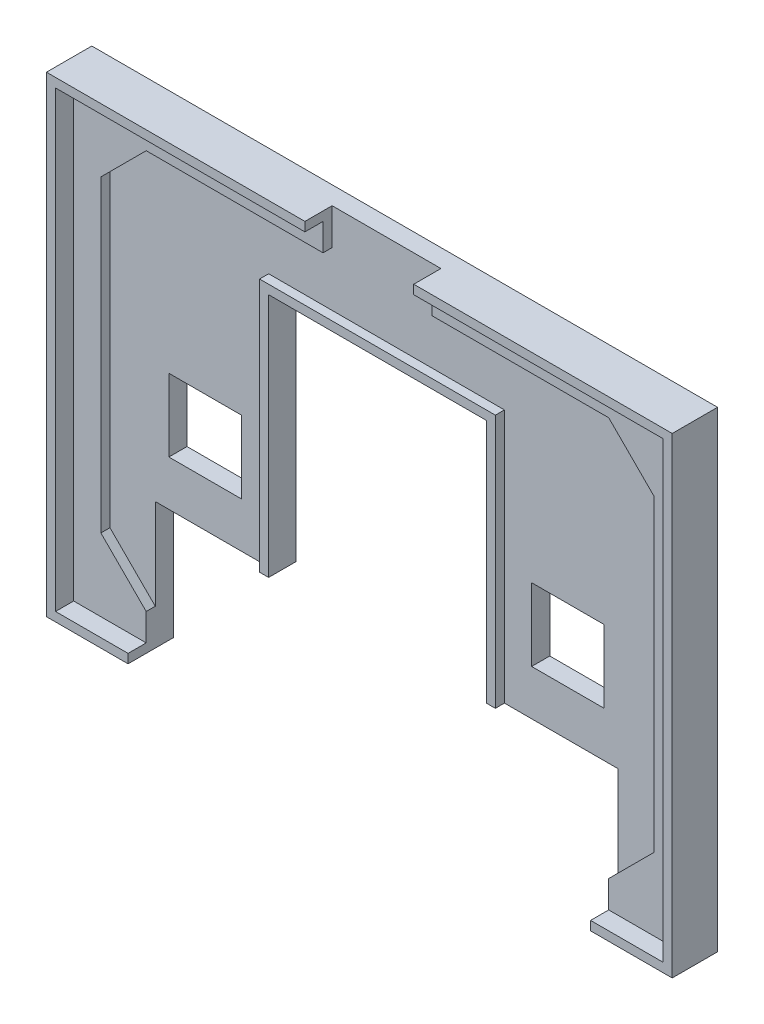
from build123d import *

# Parameters (mm, degrees)
SKICA1_W                    = 67
SKICA1_H                    = 50
P_IDAT_VYSUNUT_M1_DEPTH     = 3
ODEBRAT_VYSUNUT_M1_DEPTH    = 1
SKICA3_W                    = 8
SKICA3_H                    = 8
ODEBRAT_VYSUNUT_M2_DEPTH    = 4
VYSUNOUT_TENKOST_NN_1_DEPTH = 1
VYSUNOUT_TENKOST_NN_2_DEPTH = 5
SKICA6_W                    = 12
SKICA6_H                    = 4
ODEBRAT_VYSUNUT_M3_DEPTH    = 4
ODEBRAT_VYSUNUT_M4_DEPTH    = 1
SKICA8_W                    = 1.83786442
SKICA8_H                    = 3.44614173
SKICA8_W_2                  = 1.837864419
P_IDAT_VYSUNUT_M2_DEPTH     = 1
ODEBRAT_VYSUNUT_M5_DEPTH    = 1


with BuildPart() as part:
    # Skica1 → Přidat vysunutím1 (new body)
    with BuildSketch(Plane.XY):
        Rectangle(SKICA1_W, SKICA1_H)
    extrude(amount=P_IDAT_VYSUNUT_M1_DEPTH)

    # Skica2 → Odebrat vysunutím1 (cut)
    with BuildSketch(Plane.XY.offset(3)):
        Polygon((-25.5, -22), (-30.5, -17), (-30.5, 17), (-25.5, 22), (25.5, 22), (30.5, 17), (30.5, -17), (25.5, -22), align=None)
    extrude(amount=-ODEBRAT_VYSUNUT_M1_DEPTH, mode=Mode.SUBTRACT)

    # Skica3 → Odebrat vysunutím2 (cut, through all)
    with BuildSketch(Plane(origin=(0, 0, 0), x_dir=(-1, 0, 0), z_dir=(0, 0, -1))):
        with Locations((20, -3)):
            Rectangle(SKICA3_W, SKICA3_H)
        with Locations((-20, -3)):
            Rectangle(SKICA3_W, SKICA3_H)
        Polygon((25.5, -25), (-25.5, -25), (-25.5, -12), (-12, -12), (-12, 15), (12, 15), (12, -12), (25.5, -12), align=None)
    extrude(amount=-ODEBRAT_VYSUNUT_M2_DEPTH, mode=Mode.SUBTRACT)

    # Skica4 → Vysunout tenkostěnný1 (add)
    with BuildSketch(Plane.XY.offset(2)):
        Polygon((-12, -12), (-12, 15), (12, 15), (12, -12), (13, -12), (13, 16), (-13, 16), (-13, -12), align=None)
    extrude(amount=VYSUNOUT_TENKOST_NN_1_DEPTH)

    # Skica5 → Vysunout tenkostěnný2 (add)
    with BuildSketch(Plane(origin=(0, 0, 0), x_dir=(-1, 0, 0), z_dir=(0, 0, -1))):
        Polygon((-25.5, -25), (-33.5, -25), (-33.5, 25), (33.5, 25), (33.5, -25), (25.5, -25), (25.5, -26), (34.5, -26), (34.5, 26), (-34.5, 26), (-34.5, -26), (-25.5, -26), align=None)
    extrude(amount=-VYSUNOUT_TENKOST_NN_2_DEPTH)

    # Skica6 → Odebrat vysunutím3 (cut, through all)
    with BuildSketch(Plane.XY.offset(2)):
        with Locations((0, 24)):
            Rectangle(SKICA6_W, SKICA6_H)
    extrude(amount=ODEBRAT_VYSUNUT_M3_DEPTH, mode=Mode.SUBTRACT)

    # Skica7 → Odebrat vysunutím4 (cut)
    with BuildSketch(Plane(origin=(0, 0, 0), x_dir=(-1, 0, 0), z_dir=(0, 0, -1))):
        Polygon((-27.573500454, 21.535762152), (-25.735636034, 21.535762152), (-25.735636034, 19.662554186), (-20.752195973, 19.662554186), (-20.752195973, 21.535762152), (-18.843644461, 21.535762152), (-18.843644461, 18.001407499), (-17.111810681, 18.001407499), (-17.111810681, 16.269573719), (-15.379976901, 16.269573719), (-15.379976901, 7.433687086), (-17.111810681, 7.433687086), (-17.111810681, 10.8620111), (-18.843644461, 10.8620111), (-18.843644461, 5.737196853), (-22.377999114, 5.737196853), (-22.377999114, 7.433687086), (-20.610821787, 7.433687086), (-20.610821787, 9.077162), (-25.735636034, 9.077162), (-25.735636034, 7.433687086), (-23.968458708, 7.433687086), (-23.968458708, 5.737196853), (-27.573500454, 5.737196853), (-27.573500454, 10.8620111), (-29.34067778, 10.8620111), (-29.34067778, 7.433687086), (-31.107855107, 7.433687086), (-31.107855107, 16.269573719), (-29.34067778, 16.269573719), (-29.34067778, 18.001407499), (-27.573500454, 18.001407499), align=None)
        Polygon((22.377999114, 7.433687086), (20.610821787, 7.433687086), (20.610821787, 9.077162), (25.735636034, 9.077162), (25.735636034, 7.433687086), (23.968458708, 7.433687086), (23.968458708, 5.737196853), (27.573500454, 5.737196853), (27.573500454, 10.8620111), (29.34067778, 10.8620111), (29.34067778, 7.433687086), (31.107855107, 7.433687086), (31.107855107, 16.269573719), (29.34067778, 16.269573719), (29.34067778, 18.001407499), (27.573500454, 18.001407499), (27.573500454, 21.535762152), (25.735636034, 21.535762152), (25.735636034, 19.662554186), (20.752195973, 19.662554186), (20.752195973, 21.535762152), (18.843644461, 21.535762152), (18.843644461, 18.001407499), (17.111810681, 18.001407499), (17.111810681, 16.269573719), (15.379976901, 16.269573719), (15.379976901, 7.433687086), (17.111810681, 7.433687086), (17.111810681, 10.8620111), (18.843644461, 10.8620111), (18.843644461, 5.737196853), (22.377999114, 5.737196853), align=None)
    extrude(amount=-ODEBRAT_VYSUNUT_M4_DEPTH, mode=Mode.SUBTRACT)

    # Skica8 → Přidat vysunutím2 (add)
    with BuildSketch(Plane(origin=(0, 0, 1), x_dir=(-1, 0, 0), z_dir=(0, 0, -1))):
        with Locations((-26.654568244, 14.546502854)):
            Rectangle(SKICA8_W, SKICA8_H)
        with Locations((-19.691889577, 14.546502854)):
            Rectangle(SKICA8_W_2, SKICA8_H)
        with Locations((26.654568244, 14.546502854)):
            Rectangle(SKICA8_W, SKICA8_H)
        with Locations((19.691889577, 14.546502854)):
            Rectangle(SKICA8_W_2, SKICA8_H)
    extrude(amount=P_IDAT_VYSUNUT_M2_DEPTH)

    # Skica9 → Odebrat vysunutím5 (cut)
    with BuildSketch(Plane(origin=(0, 0, 0), x_dir=(-1, 0, 0), z_dir=(0, 0, -1))):
        with BuildLine():
            add(Edge.make_bspline(
                [(-9.537302345, 22.865597127), (-9.53696281, 22.892369552), (-9.536324143, 22.942728609), (-9.534519623, 23.0139512), (-9.529220507, 23.076239297), (-9.524308014, 23.129694286), (-9.515382011, 23.173526163), (-9.506637177, 23.209064992), (-9.494807146, 23.235008133), (-9.482756683, 23.254235867), (-9.46291792, 23.26163155), (-9.437741649, 23.267220572), (-9.400249505, 23.271288385), (-9.351541162, 23.276113687), (-9.290765442, 23.280804467), (-9.21846664, 23.285819108), (-9.134092167, 23.288841475), (-9.038213727, 23.292938181), (-8.930287005, 23.294799885), (-8.810406456, 23.297232369), (-8.678543151, 23.300109611), (-8.535059303, 23.300207146), (-8.37963407, 23.304162308), (-8.212576506, 23.302494115), (-8.033557672, 23.304964342), (-7.846934424, 23.304068462), (-7.660311177, 23.304964341), (-7.481292343, 23.30249412), (-7.31423478, 23.304162294), (-7.158809543, 23.300207193), (-7.015325708, 23.300109455), (-6.883462361, 23.297232877), (-6.763581948, 23.294798247), (-6.655654791, 23.292943383), (-6.559777713, 23.28882527), (-6.475797608, 23.285882631), (-6.403510582, 23.280691132), (-6.342726041, 23.276149909), (-6.294001793, 23.271407931), (-6.256945935, 23.26710668), (-6.232146004, 23.261635849), (-6.212319202, 23.254232462), (-6.200205343, 23.235024841), (-6.188701521, 23.208870011), (-6.178001896, 23.173785016), (-6.169745049, 23.129640249), (-6.164585879, 23.07625762), (-6.159369388, 23.013945286), (-6.15753857, 22.942730409), (-6.156903909, 22.892370177), (-6.156566504, 22.865597127)],
                knots=[0, 0, 0, 0, 8.0331e-05, 0.000151104, 0.000213628, 0.000267908, 0.000311874, 0.000347939, 0.000376911, 0.000398255, 0.000412741, 0.000438621, 0.000476093, 0.000525479, 0.000585612, 0.000658899, 0.000742895, 0.00083887, 0.000946792, 0.0010667, 0.001198595, 0.001342461, 0.00149713, 0.001664968, 0.0018436, 0.002034216, 0.002224831, 0.002403463, 0.002571301, 0.00272597, 0.002869836, 0.003001731, 0.003121639, 0.003229562, 0.003325536, 0.003409532, 0.003481623, 0.003542951, 0.003592337, 0.003628621, 0.0036545, 0.003668986, 0.003690331, 0.003719302, 0.003755704, 0.003799671, 0.003853951, 0.003916475, 0.003987247, 0.004067578, 0.004067578, 0.004067578, 0.004067578], degree=3))
            Line((-6.156566504, 22.865597127), (-6.156566504, 22.517932803))
            Line((-6.156566504, 22.517932803), (-5.891622312, 22.517932803))
            add(Edge.make_bspline(
                [(-5.891622312, 22.517932803), (-5.852723493, 22.517789452), (-5.78304439, 22.517532668), (-5.692036559, 22.503665866), (-5.621255973, 22.487521351), (-5.589784995, 22.461797975), (-5.576326735, 22.450797623)],
                knots=[0, 0, 0, 0, 0.000116343, 0.000208405, 0.000277419, 0.000328983, 0.000328983, 0.000328983, 0.000328983], degree=3))
            add(Edge.make_bspline(
                [(-5.576326735, 22.450797623), (-5.571078392, 22.438539971), (-5.556226275, 22.403852435), (-5.548489219, 22.33013994), (-5.540058826, 22.224075264), (-5.536293356, 22.126327559), (-5.534302457, 22.045593495), (-5.532715694, 21.989251146), (-5.533583626, 21.921702143), (-5.531797567, 21.842587005), (-5.530355252, 21.7518775), (-5.531281794, 21.649965942), (-5.528955975, 21.536885366), (-5.530123341, 21.412196073), (-5.527866149, 21.27593602), (-5.528435285, 21.128074363), (-5.528731851, 20.969025672), (-5.526712584, 20.798396067), (-5.527309573, 20.61656813), (-5.527134352, 20.423155484), (-5.52718652, 20.218552856), (-5.527167895, 20.006357772), (-5.527186426, 19.794162687), (-5.527134697, 19.589560061), (-5.527308031, 19.396547019), (-5.526718675, 19.214719133), (-5.528725951, 19.04448906), (-5.528434927, 18.885440407), (-5.52786641, 18.73797837), (-5.530121476, 18.601718296), (-5.528958534, 18.476629468), (-5.531282984, 18.363149186), (-5.53034846, 18.261237569), (-5.531823573, 18.170528333), (-5.533580154, 18.091413443), (-5.532715724, 18.023462852), (-5.534307395, 17.967126508), (-5.53626449, 17.886363393), (-5.540382501, 17.78932495), (-5.547637654, 17.682705023), (-5.558146632, 17.610912237), (-5.571867618, 17.563688116), (-5.59859442, 17.542295922), (-5.62702887, 17.527764426), (-5.663607461, 17.51706222), (-5.700922273, 17.513128423), (-5.739311224, 17.509734895), (-5.780936464, 17.509185174), (-5.834071768, 17.507806753), (-5.899214547, 17.506675501), (-5.97593962, 17.505547254), (-6.064250615, 17.503997914), (-6.164559488, 17.504487084), (-6.235290738, 17.504412885), (-6.272854226, 17.504373481)],
                knots=[0, 0, 0, 0, 3.9851e-05, 0.000112774, 0.000219801, 0.000360193, 0.000405765, 0.000462123, 0.000529259, 0.000608391, 0.000699511, 0.000801413, 0.00091411, 0.00103879, 0.001175463, 0.001322921, 0.001482367, 0.001652607, 0.001834831, 0.002027844, 0.002232847, 0.002448638, 0.00266443, 0.002869432, 0.003062446, 0.003243471, 0.003414909, 0.003573157, 0.003720614, 0.003857288, 0.003981967, 0.004095864, 0.004197765, 0.004287686, 0.004368018, 0.004435153, 0.004491511, 0.004537083, 0.004677476, 0.004783307, 0.00485623, 0.004897638, 0.004924817, 0.004955918, 0.004993467, 0.005038227, 0.005068294, 0.005109072, 0.005163033, 0.005227782, 0.005304517, 0.00539324, 0.005492744, 0.005605435, 0.005605435, 0.005605435, 0.005605435], degree=3))
            add(Edge.make_bspline(
                [(-6.272854226, 17.504373481), (-6.324403043, 17.504710075), (-6.420713213, 17.505338944), (-6.555837389, 17.507146882), (-6.671289532, 17.512276273), (-6.76820543, 17.517440625), (-6.845557691, 17.526035537), (-6.904848352, 17.534269772), (-6.943876859, 17.545512081), (-6.974876687, 17.561192112), (-6.98047961, 17.605365931), (-6.98927877, 17.667625557), (-6.997292171, 17.766317362), (-7.002106362, 17.896654209), (-7.008606407, 18.060641821), (-7.01298569, 18.257615902), (-7.016591708, 18.487418532), (-7.017859008, 18.651665879), (-7.018534259, 18.739181253)],
                knots=[0, 0, 0, 0, 0.000154655, 0.000288947, 0.000405334, 0.000501428, 0.000579804, 0.000639325, 0.000679517, 0.000703792, 0.000736404, 0.000801683, 0.000899151, 0.001029962, 0.001194313, 0.001390982, 0.001621188, 0.001883745, 0.001883745, 0.001883745, 0.001883745], degree=3))
            Line((-7.018534259, 18.739181253), (-7.018534259, 19.857701302))
            Line((-7.018534259, 19.857701302), (-8.67533459, 19.857701302))
            Line((-8.67533459, 19.857701302), (-8.67533459, 18.739181253))
            add(Edge.make_bspline(
                [(-8.67533459, 18.739181253), (-8.676021969, 18.651666572), (-8.67731203, 18.487420527), (-8.680770593, 18.257609466), (-8.685593662, 18.060660761), (-8.690831645, 17.896580792), (-8.699003804, 17.766447887), (-8.703592034, 17.667485718), (-8.71474526, 17.605319136), (-8.720214864, 17.561757534), (-8.75040145, 17.544793262), (-8.789652581, 17.53486673), (-8.848607616, 17.52571627), (-8.925698759, 17.517543697), (-9.022566689, 17.512239443), (-9.138035701, 17.507159253), (-9.273154314, 17.505335087), (-9.369465345, 17.504708731), (-9.421014623, 17.504373481)],
                knots=[0, 0, 0, 0, 0.000262557, 0.000492763, 0.000689432, 0.000853783, 0.000984654, 0.001082027, 0.001147471, 0.001180083, 0.00120336, 0.001244698, 0.001303037, 0.001381412, 0.001477506, 0.001593893, 0.001728185, 0.00188284, 0.00188284, 0.00188284, 0.00188284], degree=3))
            add(Edge.make_bspline(
                [(-9.421014623, 17.504373481), (-9.458578116, 17.504412698), (-9.529309373, 17.504486542), (-9.629618193, 17.503999705), (-9.717929358, 17.505541657), (-9.795053408, 17.506698175), (-9.860197757, 17.507765307), (-9.913730353, 17.509224745), (-9.955359061, 17.509704814), (-9.993749275, 17.513066496), (-10.030680832, 17.517128898), (-10.067064698, 17.528096268), (-10.096252337, 17.541942309), (-10.123174228, 17.563737006), (-10.13693763, 17.610884023), (-10.147408011, 17.682718967), (-10.154781621, 17.789318015), (-10.158471645, 17.886367346), (-10.161149191, 17.967118126), (-10.160281969, 18.023479448), (-10.162114937, 18.09140369), (-10.163495981, 18.170524728), (-10.162622963, 18.261247941), (-10.164809917, 18.363138899), (-10.164222961, 18.476635324), (-10.163958495, 18.601717143), (-10.165938682, 18.737978718), (-10.165452937, 18.885440304), (-10.165137175, 19.044489091), (-10.167151854, 19.214719124), (-10.166560324, 19.396547021), (-10.166734297, 19.589560061), (-10.166682377, 19.794162687), (-10.166700977, 20.006357772), (-10.166682283, 20.218552856), (-10.166734644, 20.423155485), (-10.166558777, 20.616568128), (-10.167157967, 20.798396076), (-10.165131254, 20.96902564), (-10.165452909, 21.128074469), (-10.165938407, 21.275935667), (-10.163958453, 21.412197241), (-10.164222472, 21.536879451), (-10.164804074, 21.649976211), (-10.162612906, 21.751867198), (-10.163508038, 21.84259042), (-10.162101412, 21.921711874), (-10.16028026, 21.989234325), (-10.161156003, 22.045602483), (-10.158433457, 22.12632027), (-10.155213791, 22.224121165), (-10.146306155, 22.330035059), (-10.13934322, 22.404212656), (-10.123264921, 22.438569033), (-10.117542114, 22.450797623)],
                knots=[0, 0, 0, 0, 0.000112691, 0.000212195, 0.000300918, 0.000377653, 0.0004436, 0.000496363, 0.000538339, 0.000568406, 0.000611979, 0.000649528, 0.000681696, 0.000708876, 0.000750283, 0.000823206, 0.000929038, 0.00106943, 0.001115002, 0.001171348, 0.001238493, 0.001318825, 0.001408738, 0.001510647, 0.001624537, 0.001749216, 0.00188589, 0.002033347, 0.002191594, 0.002363033, 0.002544058, 0.002737072, 0.002942074, 0.003157866, 0.003373657, 0.003578659, 0.003771673, 0.003953897, 0.004124137, 0.004283583, 0.004431041, 0.004567714, 0.004692394, 0.004805085, 0.004906993, 0.004998105, 0.005077238, 0.005144384, 0.00520073, 0.005246301, 0.005386694, 0.005493721, 0.005566643, 0.005606943, 0.005606943, 0.005606943, 0.005606943], degree=3))
            add(Edge.make_bspline(
                [(-10.117542114, 22.450797623), (-10.104501135, 22.46182427), (-10.073375573, 22.488142126), (-10.002078308, 22.50331256), (-9.910871706, 22.517640236), (-9.841162282, 22.517827989), (-9.802246537, 22.517932803)],
                knots=[0, 0, 0, 0, 5.0593e-05, 0.000120754, 0.000212815, 0.000329159, 0.000329159, 0.000329159, 0.000329159], degree=3))
            Line((-9.802246537, 22.517932803), (-9.537302345, 22.517932803))
            Line((-9.537302345, 22.517932803), (-9.537302345, 22.865597127))
        make_face()
        with BuildLine():
            add(Edge.make_bspline(
                [(-7.018534259, 20.951045659), (-7.018534259, 20.952644116), (-7.018534259, 20.959437557), (-7.018534259, 20.974223281), (-7.018534259, 20.999398973), (-7.018534259, 21.034165406), (-7.018534259, 21.079321807), (-7.018534259, 21.134068947), (-7.018534259, 21.198806442), (-7.018534259, 21.273534291), (-7.018534259, 21.358252494), (-7.018534259, 21.452961051), (-7.018534259, 21.557659963), (-7.018534259, 21.672349228), (-7.018534259, 21.797028848), (-7.018534259, 21.931698822), (-7.018534259, 22.07635915), (-7.018534259, 22.176262691), (-7.018534259, 22.227812919)],
                knots=[0, 0, 0, 0, 4.795e-06, 2.038e-05, 4.4357e-05, 8.0322e-05, 0.00012468, 0.000179826, 0.000244564, 0.000318892, 0.00040401, 0.000498718, 0.000603018, 0.000718107, 0.000842786, 0.000977057, 0.001122117, 0.001276767, 0.001276767, 0.001276767, 0.001276767], degree=3))
            Line((-7.018534259, 22.227812919), (-7.838542527, 22.236204816))
            add(Edge.make_bspline(
                [(-7.838542527, 22.236204816), (-7.840540598, 22.236204816), (-7.848133267, 22.236204816), (-7.865316676, 22.236204816), (-7.893689282, 22.236204816), (-7.933650698, 22.236204816), (-7.984801312, 22.236204816), (-8.047540736, 22.236204816), (-8.121469356, 22.236204816), (-8.17461804, 22.236204816), (-8.202990646, 22.236204816)],
                knots=[0, 0, 0, 0, 5.994e-06, 2.2778e-05, 5.155e-05, 9.1112e-05, 0.000142662, 0.000205002, 0.00027933, 0.000364448, 0.000364448, 0.000364448, 0.000364448], degree=3))
            add(Edge.make_bspline(
                [(-8.202990646, 22.236204816), (-8.239360634, 22.236472862), (-8.307314685, 22.236973681), (-8.40198411, 22.233758035), (-8.48240014, 22.232026014), (-8.548214262, 22.228294912), (-8.600666772, 22.224442371), (-8.637355865, 22.217365375), (-8.66367911, 22.214588369), (-8.672305795, 22.205742852), (-8.67533459, 22.202637226)],
                knots=[0, 0, 0, 0, 0.000109095, 0.000203834, 0.000284192, 0.000350226, 0.000401999, 0.000440827, 0.000464381, 0.000477125, 0.000477125, 0.000477125, 0.000477125], degree=3))
            add(Edge.make_bspline(
                [(-8.67533459, 22.202637226), (-8.67533459, 22.198641084), (-8.67533459, 22.182256904), (-8.67533459, 22.165872723), (-8.67533459, 22.153484684)],
                knots=[0, 0, 0, 0, 1.1988e-05, 4.9153e-05, 4.9153e-05, 4.9153e-05, 4.9153e-05], degree=3))
            add(Edge.make_bspline(
                [(-8.67533459, 22.153484684), (-8.67558581, 22.133898334), (-8.676155206, 22.089505427), (-8.680786555, 22.017657224), (-8.682679381, 21.937702343), (-8.683377488, 21.882546488), (-8.683726487, 21.854972902)],
                knots=[0, 0, 0, 0, 5.8756e-05, 0.000133171, 0.000215926, 0.000298654, 0.000298654, 0.000298654, 0.000298654], degree=3))
            add(Edge.make_bspline(
                [(-8.683726487, 21.854972902), (-8.683334661, 21.836191001), (-8.682350828, 21.78903161), (-8.680509978, 21.712284199), (-8.6761957, 21.631621963), (-8.675595602, 21.579243263), (-8.67533459, 21.55646112)],
                knots=[0, 0, 0, 0, 5.6358e-05, 0.00014151, 0.000230297, 0.000298642, 0.000298642, 0.000298642, 0.000298642], degree=3))
            Line((-8.67533459, 21.55646112), (-8.67533459, 20.951045659))
            Line((-8.67533459, 20.951045659), (-7.018534259, 20.951045659))
        make_face(mode=Mode.SUBTRACT)
        with BuildLine():
            add(Edge.make_bspline(
                [(-4.711961295, 22.840421434), (-4.711320941, 22.86919954), (-4.710119857, 22.923177302), (-4.706068634, 22.999075078), (-4.702883994, 23.065060265), (-4.698465504, 23.121090802), (-4.692094732, 23.16698662), (-4.686782118, 23.202781013), (-4.680229587, 23.228883735), (-4.669104594, 23.250414134), (-4.649162131, 23.268020667), (-4.619645507, 23.282079923), (-4.582919303, 23.291165632), (-4.546229992, 23.295767099), (-4.507811901, 23.299013902), (-4.466192712, 23.299533198), (-4.412656456, 23.300977555), (-4.347513445, 23.302050198), (-4.270388938, 23.303204834), (-4.182077924, 23.304747407), (-4.081769056, 23.304260374), (-4.011037806, 23.304334248), (-3.973474317, 23.304373481)],
                knots=[0, 0, 0, 0, 8.635e-05, 0.000161963, 0.000227997, 0.000284546, 0.000330495, 0.000366956, 0.000393139, 0.00041084, 0.000438827, 0.000470996, 0.000508218, 0.00055179, 0.000581857, 0.000623834, 0.000676597, 0.000742544, 0.000819279, 0.000908001, 0.001007505, 0.001120197, 0.001120197, 0.001120197, 0.001120197], degree=3))
            add(Edge.make_bspline(
                [(-3.973474317, 23.304373481), (-3.921925552, 23.304037871), (-3.82561548, 23.303410842), (-3.690490671, 23.30159102), (-3.575040448, 23.296497659), (-3.478119092, 23.291230859), (-3.40117264, 23.28295685), (-3.341861516, 23.274056024), (-3.303389913, 23.263583011), (-3.276810639, 23.250484013), (-3.27213295, 23.225023138), (-3.267509324, 23.192053258), (-3.263227671, 23.140464791), (-3.258112827, 23.071909345), (-3.255193185, 22.985469365), (-3.251458448, 22.881598237), (-3.247948038, 22.760502513), (-3.244402182, 22.621837963), (-3.240498098, 22.465599232), (-3.238556052, 22.291351276), (-3.236151724, 22.0999374), (-3.233282307, 21.890945553), (-3.233053415, 21.664350401), (-3.229648471, 21.420199551), (-3.229090161, 21.158444564), (-3.228235716, 20.978219095), (-3.227794284, 20.885109322)],
                knots=[0, 0, 0, 0, 0.000154655, 0.000288947, 0.000405334, 0.000501428, 0.000579804, 0.000638142, 0.00067948, 0.000702757, 0.000719063, 0.000752972, 0.000804745, 0.000873247, 0.000959638, 0.001063999, 0.001185136, 0.00132305, 0.001480139, 0.001653988, 0.001845818, 0.00205443, 0.002281015, 0.00252559, 0.002786941, 0.003066273, 0.003066273, 0.003066273, 0.003066273], degree=3))
            Line((-3.227794284, 20.885109322), (-3.227794284, 18.582132885))
            Line((-3.227794284, 18.582132885), (-1.695673573, 18.573740988))
            add(Edge.make_bspline(
                [(-1.695673573, 18.573740988), (-1.634133339, 18.573311829), (-1.514649223, 18.57247859), (-1.341207004, 18.571754104), (-1.179371695, 18.56895203), (-1.02911465, 18.566687148), (-0.890451989, 18.564141869), (-0.762952274, 18.562231791), (-0.647081996, 18.558264823), (-0.542776506, 18.554836158), (-0.450072632, 18.551056639), (-0.368901239, 18.548009717), (-0.299372133, 18.543047373), (-0.241486103, 18.538025357), (-0.194846131, 18.534256638), (-0.159941546, 18.527547751), (-0.13551861, 18.523302161), (-0.124329089, 18.517158125), (-0.120394532, 18.514997706)],
                knots=[0, 0, 0, 0, 0.000184626, 0.000358462, 0.000520323, 0.000670198, 0.000809284, 0.000936384, 0.001052728, 0.001157089, 0.00124947, 0.00133107, 0.001400768, 0.001458512, 0.001505512, 0.001540792, 0.001565507, 0.00157891, 0.00157891, 0.00157891, 0.00157891], degree=3))
            add(Edge.make_bspline(
                [(-0.120394532, 18.514997706), (-0.116946255, 18.509517528), (-0.108356603, 18.495866413), (-0.101084836, 18.466520486), (-0.094264664, 18.426122029), (-0.088104796, 18.372868209), (-0.085745128, 18.307594471), (-0.081059982, 18.230127383), (-0.081025461, 18.140551488), (-0.080116675, 18.076618074), (-0.079633887, 18.042653762)],
                knots=[0, 0, 0, 0, 1.9331e-05, 4.8153e-05, 8.9543e-05, 0.000142632, 0.000208666, 0.000285476, 0.000375398, 0.000477306, 0.000477306, 0.000477306, 0.000477306], degree=3))
            add(Edge.make_bspline(
                [(-0.079633887, 18.042653762), (-0.079929666, 18.009884067), (-0.080485235, 17.948332024), (-0.082828046, 17.86119743), (-0.086472147, 17.78486262), (-0.090491959, 17.71918519), (-0.097944052, 17.664381873), (-0.105975099, 17.620772637), (-0.114492161, 17.586608981), (-0.124469946, 17.569373955), (-0.128786429, 17.561917921)],
                knots=[0, 0, 0, 0, 9.8312e-05, 0.000184662, 0.000261473, 0.000327583, 0.000382008, 0.000427152, 0.000460912, 0.000486652, 0.000486652, 0.000486652, 0.000486652], degree=3))
            add(Edge.make_bspline(
                [(-0.128786429, 17.561917921), (-0.139749315, 17.555340478), (-0.1698037, 17.537308641), (-0.2386661, 17.527746589), (-0.336484571, 17.516360826), (-0.427692823, 17.513592096), (-0.502817682, 17.511473549), (-0.555566771, 17.509916033), (-0.618719986, 17.510787156), (-0.692639678, 17.508988792), (-0.776955207, 17.507557936), (-0.872073994, 17.508478198), (-0.977561204, 17.506154768), (-1.093459721, 17.507324224), (-1.220128295, 17.505058174), (-1.357200789, 17.505636139), (-1.505460006, 17.50592521), (-1.664100848, 17.503916259), (-1.83354096, 17.504507733), (-2.012967076, 17.504334273), (-2.203183603, 17.504385718), (-2.400193347, 17.504367176), (-2.597602704, 17.504385785), (-2.787819236, 17.504333578), (-2.967644953, 17.504509124), (-3.136685498, 17.503912846), (-3.294926652, 17.505928466), (-3.442786297, 17.505635168), (-3.579858783, 17.505058385), (-3.70652736, 17.507324231), (-3.822425873, 17.50615458), (-3.928312659, 17.508487646), (-4.023431551, 17.50754661), (-4.107747165, 17.509001811), (-4.181266101, 17.510787235), (-4.244423301, 17.509913643), (-4.297161042, 17.511480633), (-4.372339805, 17.513553352), (-4.462566774, 17.516806131), (-4.561773304, 17.526594574), (-4.626487111, 17.539763701), (-4.668133605, 17.554462552), (-4.680064101, 17.580100093), (-4.686855467, 17.605860943), (-4.692066228, 17.641801263), (-4.698475549, 17.687641137), (-4.702882668, 17.743691816), (-4.706059149, 17.809670405), (-4.710168314, 17.885569178), (-4.711537087, 17.957135472), (-4.713635614, 18.025060722), (-4.712736813, 18.090614456), (-4.714556047, 18.169328855), (-4.715965063, 18.261637488), (-4.71507621, 18.36714498), (-4.717272124, 18.486220819), (-4.716682545, 18.618498271), (-4.716419407, 18.764359652), (-4.718396474, 18.923000612), (-4.717912284, 19.095237703), (-4.71759214, 19.280660716), (-4.719615844, 19.479663717), (-4.719018805, 19.691861829), (-4.719194361, 19.917643308), (-4.719141989, 20.15661273), (-4.719160682, 20.404373481), (-4.719141989, 20.652134231), (-4.719194361, 20.891103653), (-4.719018805, 21.116885133), (-4.719615844, 21.329083245), (-4.71759214, 21.528086246), (-4.717912285, 21.713509259), (-4.718396471, 21.88574635), (-4.716419417, 22.04438731), (-4.716682512, 22.19024869), (-4.717272233, 22.322526145), (-4.715075867, 22.441601974), (-4.715966132, 22.547109496), (-4.714552802, 22.63941804), (-4.712746283, 22.718132701), (-4.713609385, 22.783685701), (-4.712472021, 22.822839622), (-4.711961295, 22.840421434)],
                knots=[0, 0, 0, 0, 3.8081e-05, 0.000104398, 0.000204485, 0.000335296, 0.000377273, 0.000430035, 0.000493574, 0.000566713, 0.00065184, 0.000746548, 0.000852053, 0.000968341, 0.001094225, 0.001232092, 0.001379549, 0.001539, 0.001708037, 0.001887863, 0.00207728, 0.002278686, 0.002478892, 0.002669508, 0.002849335, 0.003018372, 0.003176623, 0.003324081, 0.003461948, 0.003587832, 0.00370412, 0.003809625, 0.003905532, 0.00398946, 0.004062599, 0.004126138, 0.0041789, 0.004220877, 0.004351688, 0.004450584, 0.0045169, 0.004554981, 0.004572682, 0.004598865, 0.004635326, 0.004681275, 0.004737824, 0.004803859, 0.004879471, 0.004965821, 0.005018584, 0.005083321, 0.005162454, 0.005254773, 0.005360271, 0.005478962, 0.005612034, 0.005757094, 0.005916544, 0.006087979, 0.006273799, 0.006472811, 0.006685006, 0.006910388, 0.007150157, 0.007401914, 0.007653671, 0.007893439, 0.008118822, 0.008331017, 0.008530028, 0.008715849, 0.008887283, 0.009046734, 0.009191794, 0.009324865, 0.009443557, 0.009549055, 0.009641374, 0.009720506, 0.009785244, 0.009838006, 0.009838006, 0.009838006, 0.009838006], degree=3))
        make_face()
        with BuildLine():
            add(Edge.make_bspline(
                [(0.769146601, 23.238437143), (0.775517552, 23.246094065), (0.78891198, 23.262192145), (0.816142467, 23.276450319), (0.850857257, 23.282952791), (0.896066731, 23.288705447), (0.960504971, 23.293152303), (1.043673116, 23.296145169), (1.145155752, 23.30021321), (1.264270452, 23.301863398), (1.400122557, 23.305189598), (1.52521776, 23.304252303), (1.637108301, 23.304401451), (1.734214895, 23.304364674), (1.842510223, 23.304376243), (1.961595279, 23.304372641), (2.091469872, 23.304373734), (2.232134062, 23.304373404), (2.38358783, 23.304373505), (2.542234654, 23.304373468), (2.700881478, 23.304373505), (2.852335245, 23.304373403), (2.992999435, 23.304373735), (3.122474414, 23.304372642), (3.241159856, 23.304376223), (3.349055569, 23.304364636), (3.446162165, 23.304401562), (3.558452306, 23.304251291), (3.683947266, 23.305200868), (3.82099755, 23.301831407), (3.9413116, 23.30022894), (4.044392829, 23.296152322), (4.129155636, 23.293097311), (4.195190497, 23.2887162), (4.241616531, 23.283046394), (4.276717986, 23.27644514), (4.303949406, 23.262193392), (4.317343711, 23.246094467), (4.323714604, 23.238437143)],
                knots=[0, 0, 0, 0, 2.9682e-05, 6.2404e-05, 8.9451e-05, 0.0001354, 0.000199119, 0.000283115, 0.00038508, 0.00050379, 0.000640479, 0.000792732, 0.000879049, 0.000976155, 0.001084051, 0.001203935, 0.00133341, 0.001473674, 0.001625927, 0.001787771, 0.001949615, 0.002101868, 0.002242132, 0.002371607, 0.002490293, 0.002598189, 0.002695295, 0.002781612, 0.002935063, 0.003071753, 0.003192859, 0.003296023, 0.003381216, 0.003447327, 0.003494464, 0.003521511, 0.003554233, 0.003583915, 0.003583915, 0.003583915, 0.003583915], degree=3))
            add(Edge.make_bspline(
                [(4.323714604, 23.238437143), (4.327152092, 23.23133199), (4.335457181, 23.21416569), (4.342687706, 23.181114962), (4.349843026, 23.137941785), (4.355541833, 23.08386908), (4.360077641, 23.019502694), (4.364057064, 22.944366218), (4.36433204, 22.858799119), (4.365211318, 22.798060576), (4.365674091, 22.7660932)],
                knots=[0, 0, 0, 0, 2.3614e-05, 5.7053e-05, 0.000100807, 0.000155087, 0.000220002, 0.000294417, 0.000380742, 0.000476657, 0.000476657, 0.000476657, 0.000476657], degree=3))
            add(Edge.make_bspline(
                [(4.365674091, 22.7660932), (4.365211068, 22.732926793), (4.36433522, 22.670189783), (4.364061619, 22.582227967), (4.360130929, 22.505883898), (4.355509317, 22.441136656), (4.349967105, 22.387409522), (4.342740157, 22.345500988), (4.335911019, 22.314505563), (4.327172473, 22.299633985), (4.323714604, 22.293749256)],
                knots=[0, 0, 0, 0, 9.9511e-05, 0.000188234, 0.000263846, 0.000328761, 0.000383041, 0.000425613, 0.000456736, 0.000477117, 0.000477117, 0.000477117, 0.000477117], degree=3))
            add(Edge.make_bspline(
                [(4.323714604, 22.293749256), (4.31913811, 22.289389678), (4.307703128, 22.278496692), (4.278742041, 22.270879073), (4.239792469, 22.262554816), (4.187597151, 22.255441441), (4.123164407, 22.251388765), (4.046410577, 22.247748505), (3.957282018, 22.245446836), (3.893731452, 22.244892836), (3.859762558, 22.244596714)],
                knots=[0, 0, 0, 0, 1.8727e-05, 4.6791e-05, 8.7233e-05, 0.000139282, 0.000204197, 0.000281007, 0.000369754, 0.000471663, 0.000471663, 0.000471663, 0.000471663], degree=3))
            Line((3.859762558, 22.244596714), (3.751866733, 22.244596714))
            Line((3.751866733, 22.244596714), (3.711106088, 22.244596714))
            add(Edge.make_bspline(
                [(3.711106088, 22.244596714), (3.672342598, 22.2447201), (3.599608751, 22.244951615), (3.497713199, 22.243450037), (3.410588957, 22.242254414), (3.338665422, 22.241338419), (3.281806541, 22.2394643), (3.240388474, 22.235357209), (3.21319886, 22.233185842), (3.200775838, 22.229114903), (3.196802657, 22.227812919)],
                knots=[0, 0, 0, 0, 0.000116288, 0.000218196, 0.00030572, 0.000377661, 0.000434057, 0.000476171, 0.000502789, 0.000515305, 0.000515305, 0.000515305, 0.000515305], degree=3))
            add(Edge.make_bspline(
                [(3.196802657, 22.227812919), (3.195966953, 22.224624301), (3.193181857, 22.213997807), (3.18983773, 22.190770586), (3.18826692, 22.153889516), (3.185669839, 22.102750961), (3.18309694, 22.038017691), (3.182780252, 21.958856997), (3.179389393, 21.866181448), (3.178921577, 21.759062827), (3.177502397, 21.637984124), (3.176363033, 21.502913012), (3.175259559, 21.353856948), (3.173563002, 21.191216829), (3.174534749, 21.014181814), (3.172317482, 20.823571575), (3.17298701, 20.618566231), (3.172742239, 20.404373481), (3.172987003, 20.190180731), (3.172317506, 19.985175387), (3.174534666, 19.794565146), (3.173563278, 19.617530137), (3.175258648, 19.454889997), (3.176365995, 19.305834006), (3.177489507, 19.171162242), (3.178946152, 19.05008425), (3.179346037, 18.943363344), (3.182834506, 18.850292149), (3.183015193, 18.771522474), (3.185812394, 18.706410075), (3.188044656, 18.655625245), (3.190192343, 18.618441263), (3.192764867, 18.595447168), (3.195957568, 18.584919498), (3.196802657, 18.582132885)],
                knots=[0, 0, 0, 0, 9.886e-06, 3.2946e-05, 7.0187e-05, 0.000120596, 0.000186576, 0.00026451, 0.00035805, 0.000464754, 0.000585843, 0.000721318, 0.000869979, 0.001033026, 0.001209256, 0.001401074, 0.001604877, 0.001824266, 0.002043654, 0.002247457, 0.002439276, 0.002615505, 0.002778552, 0.002927214, 0.003062688, 0.003182578, 0.003290481, 0.003382823, 0.003461956, 0.003526738, 0.003578343, 0.003614389, 0.003638634, 0.003647361, 0.003647361, 0.003647361, 0.003647361], degree=3))
            add(Edge.make_bspline(
                [(3.196802657, 18.582132885), (3.200775805, 18.580829834), (3.213198724, 18.576755556), (3.24039013, 18.574642266), (3.281782347, 18.570108986), (3.33871528, 18.570727635), (3.410558183, 18.566919453), (3.497720264, 18.566758183), (3.599606564, 18.56491297), (3.672341838, 18.565197468), (3.711106088, 18.565349091)],
                knots=[0, 0, 0, 0, 1.2516e-05, 3.9135e-05, 8.1248e-05, 0.000137607, 0.000209577, 0.000297101, 0.000399009, 0.000515297, 0.000515297, 0.000515297, 0.000515297], degree=3))
            Line((3.711106088, 18.565349091), (3.751866733, 18.565349091))
            Line((3.751866733, 18.565349091), (3.859762558, 18.565349091))
            add(Edge.make_bspline(
                [(3.859762558, 18.565349091), (3.893732062, 18.565055652), (3.95728377, 18.564506673), (4.046404942, 18.562172514), (4.123181301, 18.558631356), (4.187548934, 18.55429226), (4.2400093, 18.547945303), (4.278592132, 18.537616567), (4.307711168, 18.530286036), (4.319140408, 18.519367506), (4.323714604, 18.514997706)],
                knots=[0, 0, 0, 0, 0.000101909, 0.000190655, 0.000267466, 0.00033238, 0.00038443, 0.000425138, 0.000453202, 0.000471929, 0.000471929, 0.000471929, 0.000471929], degree=3))
            add(Edge.make_bspline(
                [(4.323714604, 18.514997706), (4.327172278, 18.509112958), (4.335910332, 18.494241332), (4.342745387, 18.46324648), (4.349869534, 18.421724639), (4.355601594, 18.368420477), (4.360150311, 18.303661923), (4.364037621, 18.226917737), (4.364342103, 18.138557325), (4.365213448, 18.075820219), (4.365674091, 18.042653762)],
                knots=[0, 0, 0, 0, 2.038e-05, 5.1504e-05, 9.4076e-05, 0.000147164, 0.000212079, 0.000288889, 0.000377612, 0.000477123, 0.000477123, 0.000477123, 0.000477123], degree=3))
            add(Edge.make_bspline(
                [(4.365674091, 18.042653762), (4.365218513, 18.010686045), (4.364358601, 17.950346381), (4.363987516, 17.864784127), (4.360190954, 17.790034882), (4.355453871, 17.725686937), (4.349905429, 17.671989226), (4.342469322, 17.628488249), (4.335671854, 17.594920821), (4.327165238, 17.577412083), (4.323714604, 17.570309818)],
                knots=[0, 0, 0, 0, 9.5915e-05, 0.000181041, 0.000256654, 0.000320373, 0.000374653, 0.000418407, 0.000453007, 0.000476622, 0.000476622, 0.000476622, 0.000476622], degree=3))
            add(Edge.make_bspline(
                [(4.323714604, 17.570309818), (4.317344214, 17.56264821), (4.303950966, 17.546540276), (4.276711502, 17.532357061), (4.241687248, 17.525490955), (4.195071334, 17.521831766), (4.129150338, 17.516911212), (4.044428707, 17.512137408), (3.941306023, 17.508675533), (3.820999369, 17.506864201), (3.683946674, 17.503562808), (3.558452393, 17.504493202), (3.446162145, 17.504345967), (3.349055576, 17.504382146), (3.241159854, 17.504370794), (3.122474415, 17.504374303), (2.992999435, 17.504373232), (2.852335246, 17.504373556), (2.700881478, 17.504373457), (2.542234654, 17.504373493), (2.38358783, 17.504373457), (2.232134062, 17.504373556), (2.091469873, 17.504373233), (1.961595278, 17.504374303), (1.842510225, 17.504370776), (1.734214888, 17.504382105), (1.637108322, 17.504346091), (1.525217671, 17.504492145), (1.400123157, 17.50357429), (1.264268607, 17.506831506), (1.145161303, 17.508690382), (1.04363689, 17.512143078), (0.96050941, 17.51684667), (0.896187846, 17.521833019), (0.850783927, 17.525578342), (0.816149413, 17.532354311), (0.788910308, 17.546540938), (0.775517013, 17.562648423), (0.769146601, 17.570309818)],
                knots=[0, 0, 0, 0, 2.9682e-05, 6.2404e-05, 8.9451e-05, 0.000136451, 0.000202562, 0.000287815, 0.000390978, 0.000512084, 0.000648774, 0.000802225, 0.000888542, 0.000985648, 0.001093544, 0.00121223, 0.001341705, 0.001481969, 0.001634222, 0.001796066, 0.00195791, 0.002110163, 0.002250427, 0.002379902, 0.002499786, 0.002607682, 0.002704788, 0.002791105, 0.002943358, 0.003080047, 0.003198757, 0.003300722, 0.003384778, 0.003448497, 0.003494305, 0.003521352, 0.003554074, 0.003583756, 0.003583756, 0.003583756, 0.003583756], degree=3))
            add(Edge.make_bspline(
                [(0.769146601, 17.570309818), (0.765693304, 17.577411817), (0.757180124, 17.594919897), (0.750456188, 17.628494687), (0.742621867, 17.671916005), (0.739132202, 17.725779471), (0.733686988, 17.790016673), (0.730131636, 17.864790037), (0.729683648, 17.950344601), (0.72883537, 18.010685428), (0.728385956, 18.042653762)],
                knots=[0, 0, 0, 0, 2.3614e-05, 5.8215e-05, 0.000101969, 0.000156129, 0.000219849, 0.000295461, 0.000380588, 0.000476503, 0.000476503, 0.000476503, 0.000476503], degree=3))
            add(Edge.make_bspline(
                [(0.728385956, 18.042653762), (0.728130922, 18.076624162), (0.727650778, 18.140579099), (0.730775458, 18.230076658), (0.732786727, 18.30762321), (0.735910581, 18.372832515), (0.741341584, 18.42590452), (0.744788463, 18.46661445), (0.751706652, 18.495272701), (0.758213515, 18.509457844), (0.760754703, 18.514997706)],
                knots=[0, 0, 0, 0, 0.000101902, 0.000191847, 0.00026861, 0.000334644, 0.000387611, 0.000428653, 0.000457149, 0.000475409, 0.000475409, 0.000475409, 0.000475409], degree=3))
            add(Edge.make_bspline(
                [(0.760754703, 18.514997706), (0.765326837, 18.519378151), (0.777026702, 18.530587497), (0.807167652, 18.537445331), (0.846848929, 18.547974881), (0.9001331, 18.554198013), (0.965278171, 18.55869251), (1.043261234, 18.562178138), (1.133979083, 18.564492171), (1.198729474, 18.565051958), (1.233098647, 18.565349091)],
                knots=[0, 0, 0, 0, 1.8727e-05, 4.792e-05, 8.9794e-05, 0.000143031, 0.000207946, 0.000285954, 0.000377097, 0.000480205, 0.000480205, 0.000480205, 0.000480205], degree=3))
            Line((1.233098647, 18.565349091), (1.340994472, 18.565349091))
            Line((1.340994472, 18.565349091), (1.382953959, 18.565349091))
            add(Edge.make_bspline(
                [(1.382953959, 18.565349091), (1.421718198, 18.565198241), (1.494453452, 18.564915193), (1.595940389, 18.566743802), (1.682702084, 18.566941212), (1.754145909, 18.570727519), (1.811078861, 18.570109006), (1.852471074, 18.574642263), (1.879662481, 18.576755556), (1.8920854, 18.580829834), (1.896058548, 18.582132885)],
                knots=[0, 0, 0, 0, 0.000116288, 0.000218196, 0.000304521, 0.000376492, 0.00043285, 0.000474964, 0.000501582, 0.000514098, 0.000514098, 0.000514098, 0.000514098], degree=3))
            add(Edge.make_bspline(
                [(1.896058548, 18.582132885), (1.896958442, 18.584913434), (1.900086747, 18.594579464), (1.898946255, 18.617057785), (1.903235725, 18.652743155), (1.903062184, 18.703250021), (1.904363496, 18.767954403), (1.90743363, 18.846659867), (1.907893783, 18.939389695), (1.90974626, 19.046079537), (1.908816241, 19.167172028), (1.91056365, 19.30223666), (1.912061894, 19.451290551), (1.911146691, 19.61433934), (1.913354231, 19.791761876), (1.912688457, 19.983580282), (1.912890766, 20.189380916), (1.912817395, 20.404373481), (1.912890713, 20.619366045), (1.912688649, 20.825166681), (1.913353585, 21.016985081), (1.911148831, 21.194407638), (1.912057096, 21.357855967), (1.91057986, 21.506910055), (1.908812024, 21.641974471), (1.90975204, 21.762667542), (1.907872774, 21.86975647), (1.907475179, 21.962487857), (1.904336118, 22.041190899), (1.903084721, 22.105498295), (1.903185356, 22.156400214), (1.898952663, 22.192485687), (1.900084986, 22.215366162), (1.896958049, 22.22503233), (1.896058548, 22.227812919)],
                knots=[0, 0, 0, 0, 8.728e-06, 3.034e-05, 6.6385e-05, 0.000116751, 0.0001815, 0.000260659, 0.000352978, 0.000459682, 0.000580765, 0.000716239, 0.000864901, 0.001027943, 0.001205376, 0.001397191, 0.001603392, 0.00182278, 0.002042168, 0.002248369, 0.002440184, 0.002617617, 0.002780659, 0.002930519, 0.003064795, 0.003185878, 0.003292582, 0.003386099, 0.003464061, 0.003528809, 0.003579175, 0.003616416, 0.003638029, 0.003646757, 0.003646757, 0.003646757, 0.003646757], degree=3))
            add(Edge.make_bspline(
                [(1.896058548, 22.227812919), (1.892085367, 22.229114902), (1.879662345, 22.23318584), (1.852472731, 22.235357233), (1.811054662, 22.239464133), (1.754195789, 22.241339366), (1.682671626, 22.242244352), (1.595947418, 22.243463095), (1.494451265, 22.244949384), (1.421717438, 22.244719324), (1.382953959, 22.244596714)],
                knots=[0, 0, 0, 0, 1.2516e-05, 3.9135e-05, 8.1248e-05, 0.000137645, 0.000209585, 0.00029591, 0.000397819, 0.000514107, 0.000514107, 0.000514107, 0.000514107], degree=3))
            Line((1.382953959, 22.244596714), (1.340994472, 22.244596714))
            Line((1.340994472, 22.244596714), (1.233098647, 22.244596714))
            add(Edge.make_bspline(
                [(1.233098647, 22.244596714), (1.198730054, 22.244896473), (1.133980755, 22.245461209), (1.043255786, 22.247742974), (0.965294204, 22.251325965), (0.900087731, 22.255542157), (0.847059139, 22.262523956), (0.807020383, 22.271043308), (0.777034304, 22.278194351), (0.765328973, 22.289378613), (0.760754703, 22.293749256)],
                knots=[0, 0, 0, 0, 0.000103107, 0.000194251, 0.000272259, 0.000337174, 0.000390411, 0.000432026, 0.00046122, 0.000479947, 0.000479947, 0.000479947, 0.000479947], degree=3))
            add(Edge.make_bspline(
                [(0.760754703, 22.293749256), (0.7582023, 22.299286594), (0.751504356, 22.313817514), (0.745003563, 22.342990298), (0.741265991, 22.384023214), (0.735993793, 22.436723651), (0.732702664, 22.501917208), (0.730839412, 22.57907273), (0.727627604, 22.668566391), (0.728121805, 22.732122459), (0.728385956, 22.7660932)],
                knots=[0, 0, 0, 0, 1.826e-05, 4.7918e-05, 8.896e-05, 0.000141926, 0.000206764, 0.000284725, 0.000373472, 0.000475374, 0.000475374, 0.000475374, 0.000475374], degree=3))
            add(Edge.make_bspline(
                [(0.728385956, 22.7660932), (0.728842562, 22.798061193), (0.729710122, 22.858800908), (0.730062661, 22.944360251), (0.733802283, 23.019520705), (0.739055728, 23.083775397), (0.742684472, 23.138015008), (0.750235247, 23.181108781), (0.757394954, 23.214166598), (0.765706458, 23.231332255), (0.769146601, 23.238437143)],
                knots=[0, 0, 0, 0, 9.5915e-05, 0.00018224, 0.000256655, 0.00032157, 0.000375731, 0.000419484, 0.000452923, 0.000476538, 0.000476538, 0.000476538, 0.000476538], degree=3))
        make_face()
        with BuildLine():
            add(Edge.make_bspline(
                [(5.185682359, 22.840421434), (5.186322712, 22.869199544), (5.187523791, 22.923177314), (5.191575039, 22.99907504), (5.194759602, 23.06506038), (5.199178319, 23.121090467), (5.205548463, 23.166987533), (5.210862715, 23.202778671), (5.217411408, 23.228889018), (5.228547064, 23.250398229), (5.248702443, 23.268373118), (5.279295809, 23.281983168), (5.317501089, 23.291305994), (5.355823665, 23.295716448), (5.395427817, 23.298977196), (5.437444984, 23.299546372), (5.490582198, 23.300956793), (5.555324852, 23.302069135), (5.631650699, 23.303189653), (5.719162133, 23.304751023), (5.817872688, 23.30426045), (5.887405083, 23.304334388), (5.924169337, 23.304373481)],
                knots=[0, 0, 0, 0, 8.635e-05, 0.000161963, 0.000227997, 0.000284546, 0.000330495, 0.000366956, 0.000393139, 0.00041084, 0.000438827, 0.000472072, 0.000510454, 0.000556403, 0.000587665, 0.000629641, 0.000682404, 0.000747153, 0.000823888, 0.000911412, 0.001009717, 0.00112001, 0.00112001, 0.00112001, 0.00112001], degree=3))
            add(Edge.make_bspline(
                [(5.924169337, 23.304373481), (5.97412222, 23.304078194), (6.068039498, 23.303523021), (6.199922116, 23.301189554), (6.313432343, 23.297703743), (6.408605341, 23.293272767), (6.485544827, 23.286977109), (6.543857696, 23.276820847), (6.58465895, 23.26916373), (6.611515439, 23.256521154), (6.625275114, 23.235357826), (6.633660053, 23.207973213), (6.643677683, 23.172578613), (6.650462962, 23.127136963), (6.654644885, 23.072652876), (6.658262369, 23.009094363), (6.660617322, 22.936345041), (6.661164733, 22.884780491), (6.661457473, 22.857205229)],
                knots=[0, 0, 0, 0, 0.00014986, 0.000281755, 0.000395701, 0.000490531, 0.000567594, 0.000627115, 0.000667822, 0.000692508, 0.000713134, 0.000741198, 0.00077842, 0.000823357, 0.000878711, 0.000942352, 0.001014322, 0.001097051, 0.001097051, 0.001097051, 0.001097051], degree=3))
            Line((6.661457473, 22.857205229), (6.661457473, 22.517932803))
            Line((6.661457473, 22.517932803), (6.934793562, 22.517932803))
            Line((6.934793562, 22.517932803), (6.94318546, 22.517932803))
            add(Edge.make_bspline(
                [(6.94318546, 22.517932803), (6.981554349, 22.517307978), (7.049657072, 22.516198946), (7.139198762, 22.507600626), (7.20317961, 22.493438665), (7.250878255, 22.466212525), (7.270563544, 22.40865534), (7.282713916, 22.328197358), (7.290225607, 22.211021895), (7.290624097, 22.121478231), (7.290849784, 22.070764551)],
                knots=[0, 0, 0, 0, 0.000115145, 0.000204376, 0.000268936, 0.000312161, 0.000360976, 0.000442577, 0.000559167, 0.000711439, 0.000711439, 0.000711439, 0.000711439], degree=3))
            Line((7.290849784, 22.070764551), (7.290849784, 21.721901385))
            Line((7.290849784, 21.721901385), (7.564185873, 21.721901385))
            Line((7.564185873, 21.721901385), (7.580969668, 21.721901385))
            Line((7.580969668, 21.721901385), (7.614537258, 21.721901385))
            add(Edge.make_bspline(
                [(7.614537258, 21.721901385), (7.648085465, 21.721071766), (7.707330261, 21.719606691), (7.786006572, 21.713093635), (7.84148057, 21.697995216), (7.883304506, 21.673287537), (7.899934483, 21.623571032), (7.912110236, 21.555338098), (7.919551924, 21.457384666), (7.919994158, 21.382598295), (7.920242095, 21.340669471)],
                knots=[0, 0, 0, 0, 0.000100767, 0.00017795, 0.000235595, 0.000273505, 0.000316962, 0.000385381, 0.000484043, 0.000609944, 0.000609944, 0.000609944, 0.000609944], degree=3))
            Line((7.920242095, 21.340669471), (7.920242095, 21.283125031))
            Line((7.920242095, 21.283125031), (7.920242095, 20.935460707))
            add(Edge.make_bspline(
                [(7.920242095, 20.935460707), (7.94861616, 20.936209978), (8.016570643, 20.938004446), (8.124083937, 20.942205144), (8.231087122, 20.948823675), (8.298670699, 20.950395102), (8.326649701, 20.951045659)],
                knots=[0, 0, 0, 0, 8.5152e-05, 0.000203934, 0.000322771, 0.000406724, 0.000406724, 0.000406724, 0.000406724], degree=3))
            Line((8.326649701, 20.951045659), (8.326649701, 22.070764551))
            add(Edge.make_bspline(
                [(8.326649701, 22.070764551), (8.327325169, 22.158279895), (8.328592874, 22.322527186), (8.332196263, 22.552330179), (8.336583459, 22.749303167), (8.343060992, 22.91329389), (8.347935047, 23.043622463), (8.355772024, 23.141934535), (8.364783714, 23.203799889), (8.370303965, 23.247556309), (8.401308452, 23.263234284), (8.440334946, 23.274477482), (8.499626545, 23.282711303), (8.576978428, 23.291306382), (8.673894465, 23.296470672), (8.789346559, 23.301600085), (8.924470751, 23.303408016), (9.020780918, 23.304036886), (9.072329734, 23.304373481)],
                knots=[0, 0, 0, 0, 0.000262557, 0.000492763, 0.000689432, 0.000853783, 0.000984594, 0.001082062, 0.001146153, 0.001178765, 0.001203039, 0.001243232, 0.001302753, 0.001381128, 0.001477223, 0.001593609, 0.001727901, 0.001882556, 0.001882556, 0.001882556, 0.001882556], degree=3))
            add(Edge.make_bspline(
                [(9.072329734, 23.304373481), (9.109893219, 23.30433406), (9.180624461, 23.304259832), (9.280933382, 23.304749198), (9.369244226, 23.303199237), (9.445969754, 23.302072864), (9.511111207, 23.300936154), (9.564250209, 23.299572951), (9.605866085, 23.298984699), (9.644283081, 23.29570656), (9.681351217, 23.2912157), (9.718272625, 23.282397561), (9.747026789, 23.26765131), (9.766771018, 23.2504334), (9.777882891, 23.228877335), (9.784440143, 23.20278385), (9.789750745, 23.166985516), (9.796122271, 23.121091203), (9.800540575, 23.065060155), (9.803724869, 22.999074988), (9.807778086, 22.923177911), (9.809362835, 22.851612926), (9.810894593, 22.78367898), (9.812473133, 22.718146872), (9.811595691, 22.639409879), (9.813379356, 22.547106456), (9.814829848, 22.441610853), (9.81390403, 22.32251733), (9.816222715, 22.190253691), (9.815064195, 22.044386325), (9.817315304, 21.885746646), (9.816748599, 21.71350917), (9.816453255, 21.528086272), (9.818469578, 21.329083237), (9.817874717, 21.116885135), (9.818049632, 20.891103652), (9.817997451, 20.652134231), (9.818016076, 20.404373481), (9.817997451, 20.15661273), (9.818049632, 19.917643309), (9.817874717, 19.691861827), (9.818469578, 19.479663724), (9.816453255, 19.280660689), (9.816748599, 19.095237792), (9.817315304, 18.923000315), (9.815064195, 18.764360637), (9.816222715, 18.61849327), (9.81390403, 18.486229632), (9.814829848, 18.367136109), (9.813379356, 18.261640506), (9.81159569, 18.169337083), (9.812473135, 18.090600088), (9.810894589, 18.025067986), (9.809362853, 17.957134019), (9.807777978, 17.885569154), (9.803725196, 17.809671663), (9.800539588, 17.743687749), (9.796125141, 17.68765302), (9.789742929, 17.641768902), (9.784460196, 17.605943979), (9.777837656, 17.579912785), (9.767030025, 17.558427803), (9.746336627, 17.542023511), (9.716865517, 17.527841051), (9.679172087, 17.517051677), (9.641056057, 17.513188574), (9.601879376, 17.509689358), (9.559850354, 17.509217407), (9.506317203, 17.507798014), (9.441573369, 17.50668962), (9.365647923, 17.505542081), (9.278136126, 17.503993308), (9.179026017, 17.504486234), (9.109093996, 17.504412332), (9.072329734, 17.504373481)],
                knots=[0, 0, 0, 0, 0.000112691, 0.000212195, 0.000300918, 0.000377653, 0.000442401, 0.000496363, 0.000537141, 0.000567208, 0.000611968, 0.00064919, 0.000680291, 0.000708278, 0.000725979, 0.000752162, 0.000788623, 0.000834572, 0.000891121, 0.000957156, 0.001032768, 0.001119118, 0.001171881, 0.00123663, 0.001315753, 0.001408072, 0.001513577, 0.001632262, 0.001765339, 0.001910399, 0.00206985, 0.002241284, 0.002427105, 0.002626116, 0.002838311, 0.003063694, 0.003303462, 0.003555219, 0.003806976, 0.004046744, 0.004272127, 0.004484322, 0.004683333, 0.004869154, 0.005040588, 0.005200039, 0.005345099, 0.005478176, 0.005596861, 0.005702366, 0.005794685, 0.005873809, 0.005938557, 0.00599132, 0.00607767, 0.006153282, 0.006219317, 0.006275866, 0.006321815, 0.006358276, 0.006384459, 0.00640216, 0.00642934, 0.006461508, 0.006500207, 0.006546155, 0.006576222, 0.006618199, 0.00667216, 0.006736908, 0.006812445, 0.006899969, 0.006999473, 0.007109766, 0.007109766, 0.007109766, 0.007109766], degree=3))
            add(Edge.make_bspline(
                [(9.072329734, 17.504373481), (9.022376557, 17.504670736), (8.928458727, 17.505229611), (8.796579713, 17.507538953), (8.683058529, 17.511098108), (8.587916854, 17.515319422), (8.510952202, 17.522182219), (8.452912955, 17.530883252), (8.411069175, 17.537536555), (8.392429403, 17.549144197), (8.385392984, 17.553526023)],
                knots=[0, 0, 0, 0, 0.00014986, 0.000281755, 0.000395701, 0.000490531, 0.000567594, 0.000626933, 0.000667641, 0.000692327, 0.000692327, 0.000692327, 0.000692327], degree=3))
            add(Edge.make_bspline(
                [(8.385392984, 17.553526023), (8.380997929, 17.561780418), (8.369265068, 17.58381602), (8.363141629, 17.631544896), (8.351783738, 17.698105311), (8.34834838, 17.786973989), (8.340976246, 17.895882608), (8.338463865, 18.025873091), (8.335818394, 18.176510491), (8.335311206, 18.284017627), (8.335041599, 18.341165544)],
                knots=[0, 0, 0, 0, 2.7884e-05, 7.4439e-05, 0.000142256, 0.000231172, 0.000340432, 0.000469957, 0.00062103, 0.000792468, 0.000792468, 0.000792468, 0.000792468], degree=3))
            Line((8.335041599, 18.341165544), (8.335041599, 19.086845577))
            Line((8.335041599, 19.086845577), (8.061705509, 19.086845577))
            Line((8.061705509, 19.086845577), (8.053313612, 19.086845577))
            Line((8.053313612, 19.086845577), (8.019746022, 19.086845577))
            add(Edge.make_bspline(
                [(8.019746022, 19.086845577), (7.98493236, 19.087264018), (7.923479745, 19.088002645), (7.842501499, 19.098665332), (7.783708306, 19.113385034), (7.740500304, 19.143446526), (7.724532086, 19.200545154), (7.714541402, 19.279599941), (7.706046751, 19.392513658), (7.705792317, 19.47848981), (7.705649288, 19.526820773)],
                knots=[0, 0, 0, 0, 0.000104361, 0.000184217, 0.000244506, 0.000285513, 0.000334489, 0.000414516, 0.000527519, 0.000672599, 0.000672599, 0.000672599, 0.000672599], degree=3))
            Line((7.705649288, 19.526820773), (7.705649288, 19.874485097))
            Line((7.705649288, 19.874485097), (7.432313199, 19.874485097))
            Line((7.432313199, 19.874485097), (7.415529404, 19.874485097))
            add(Edge.make_bspline(
                [(7.415529404, 19.874485097), (7.37838735, 19.875289227), (7.312369599, 19.876718518), (7.225067587, 19.883534186), (7.163097031, 19.897409213), (7.11569088, 19.920699465), (7.095640525, 19.972732596), (7.085161436, 20.043620056), (7.07499645, 20.144078446), (7.075035955, 20.220950542), (7.075058134, 20.264108909)],
                knots=[0, 0, 0, 0, 0.00011155, 0.000198274, 0.00026137, 0.000303312, 0.000348884, 0.000419656, 0.000520815, 0.000650312, 0.000650312, 0.000650312, 0.000650312], degree=3))
            Line((7.075058134, 20.264108909), (7.075058134, 20.321653348))
            Line((7.075058134, 20.321653348), (7.075058134, 20.669317673))
            add(Edge.make_bspline(
                [(7.075058134, 20.669317673), (7.047079096, 20.668658367), (6.97949543, 20.667065808), (6.87245288, 20.660654181), (6.765167211, 20.655700296), (6.697803054, 20.648378926), (6.66984937, 20.645340823)],
                knots=[0, 0, 0, 0, 8.3953e-05, 0.00020279, 0.000321693, 0.000406031, 0.000406031, 0.000406031, 0.000406031], degree=3))
            Line((6.66984937, 20.645340823), (6.66984937, 19.128805064))
            add(Edge.make_bspline(
                [(6.66984937, 19.128805064), (6.669407423, 19.067664604), (6.668552414, 18.949379616), (6.668002128, 18.777933253), (6.664586263, 18.6181082), (6.66435308, 18.46943062), (6.661504782, 18.331972629), (6.659074605, 18.205697089), (6.657144982, 18.090583311), (6.653218785, 17.986700989), (6.64971768, 17.894388382), (6.646177764, 17.8136557), (6.642410654, 17.744146591), (6.639523214, 17.685676619), (6.634366538, 17.6386423), (6.630077553, 17.602793609), (6.625314994, 17.578692626), (6.619958027, 17.557874921), (6.594330226, 17.545175857), (6.555745867, 17.534685292), (6.49648625, 17.525792483), (6.419518869, 17.517515217), (6.322605241, 17.51224962), (6.2071523, 17.507155835), (6.072028387, 17.505336153), (5.975718176, 17.504709102), (5.924169337, 17.504373481)],
                knots=[0, 0, 0, 0, 0.000183427, 0.000354865, 0.00051433, 0.000662991, 0.000800879, 0.00092678, 0.001041894, 0.001146255, 0.001238636, 0.001319039, 0.001388665, 0.001447518, 0.001494518, 0.001530802, 0.001555253, 0.001569285, 0.001592563, 0.001633901, 0.001692239, 0.001770615, 0.001866709, 0.001983096, 0.002117387, 0.002272043, 0.002272043, 0.002272043, 0.002272043], degree=3))
            add(Edge.make_bspline(
                [(5.924169337, 17.504373481), (5.886605845, 17.504412698), (5.815874587, 17.504486543), (5.715565766, 17.503999702), (5.627254606, 17.505541665), (5.550130542, 17.506698152), (5.484986231, 17.507765375), (5.431453532, 17.509224563), (5.389825092, 17.509705284), (5.351434094, 17.513065055), (5.314506308, 17.51713665), (5.278109906, 17.528073454), (5.248959227, 17.542009618), (5.228270866, 17.558429902), (5.217462348, 17.579912077), (5.210840147, 17.605944293), (5.205557177, 17.641768779), (5.199175544, 17.687653069), (5.194758429, 17.743687713), (5.19158535, 17.809671761), (5.18747506, 17.885568727), (5.186106613, 17.957135545), (5.184008028, 18.025060702), (5.184906846, 18.090614463), (5.183087606, 18.169328852), (5.181678591, 18.261637488), (5.182567444, 18.36714498), (5.18037153, 18.486220819), (5.180961109, 18.618498271), (5.181224247, 18.764359652), (5.17924718, 18.923000612), (5.179731371, 19.095237703), (5.180051515, 19.280660716), (5.178027811, 19.479663717), (5.178624849, 19.691861829), (5.178449294, 19.917643308), (5.178501666, 20.15661273), (5.178482973, 20.404373481), (5.178501666, 20.652134231), (5.178449294, 20.891103653), (5.178624849, 21.116885133), (5.178027811, 21.329083245), (5.180051515, 21.528086246), (5.17973137, 21.713509259), (5.179247184, 21.88574635), (5.181224237, 22.04438731), (5.180961143, 22.19024869), (5.180371421, 22.322526145), (5.182567787, 22.441601974), (5.181677523, 22.547109496), (5.183090853, 22.63941804), (5.184897371, 22.718132701), (5.184034269, 22.783685701), (5.185171633, 22.822839622), (5.185682359, 22.840421434)],
                knots=[0, 0, 0, 0, 0.000112691, 0.000212195, 0.000300918, 0.000377653, 0.0004436, 0.000496363, 0.000538339, 0.000568406, 0.000611979, 0.000649528, 0.000681696, 0.000708876, 0.000726576, 0.000752759, 0.000789221, 0.000835169, 0.000891719, 0.000957753, 0.001033366, 0.001119716, 0.001172478, 0.001237216, 0.001316349, 0.001408667, 0.001514165, 0.001632857, 0.001765928, 0.001910988, 0.002070439, 0.002241873, 0.002427694, 0.002626705, 0.002838901, 0.003064283, 0.003304051, 0.003555808, 0.003807565, 0.004047334, 0.004272716, 0.004484911, 0.004683923, 0.004869743, 0.005041178, 0.005200628, 0.005345688, 0.00547876, 0.005597451, 0.005702949, 0.005795268, 0.005874401, 0.005939138, 0.005991901, 0.005991901, 0.005991901, 0.005991901], degree=3))
        make_face()
    extrude(amount=-ODEBRAT_VYSUNUT_M5_DEPTH, mode=Mode.SUBTRACT)


solid = part.part
